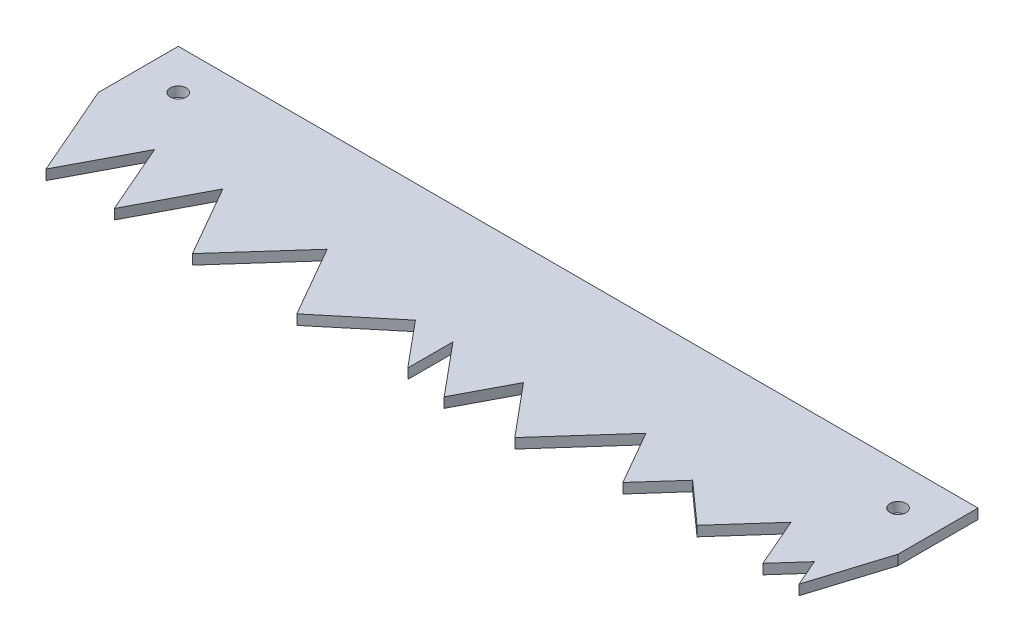
from build123d import *

# Parameters (mm, degrees)
SKETCH1_W           = 254
SKETCH1_H           = 25.4
BOSS_EXTRUDE1_DEPTH = 3.175
BOSS_EXTRUDE2_DEPTH = 3.175
SKETCH3_R           = 2.54
CUT_EXTRUDE2_DEPTH  = 4.175


with BuildPart() as part:
    # Sketch1 → Boss-Extrude1 (new body)
    with BuildSketch(Plane(origin=(0, 0, 0), x_dir=(1, 0, 0), z_dir=(0, 1, 0))):
        Rectangle(SKETCH1_W, SKETCH1_H)
    extrude(amount=BOSS_EXTRUDE1_DEPTH)

    # Sketch2 → Boss-Extrude2 (add)
    with BuildSketch(Plane(origin=(0, 3.175, 0), x_dir=(1, 0, 0), z_dir=(0, 1, 0))):
        Polygon((-127, -12.7), (-114.24505896, -42.072282192), (-102.377802862, -19.463351482), (-92.559853535, -42.072282192), (-80.692597436, -19.463351482), (-67.726112797, -42.072282192), (-47.545099388, -19.463351482), (-34.578614749, -42.072282192), (-14.024094064, -24.969728455), (-2.091376305, -39.310937246), (-2.091376305, -24.969728455), (11.649477697, -41.484026388), (20.317707317, -24.969728455), (34.058561319, -41.484026388), (53.714490264, -19.463351482), (63.583568446, -36.671508588), (74.028723274, -24.969728455), (87.13830954, -36.671508588), (101.210719192, -20.906089464), (108.056867206, -36.671508588), (115.76466778, -28.036405605), (119.514469334, -36.671508588), (127, -12.7), align=None)
    extrude(amount=-BOSS_EXTRUDE2_DEPTH)

    # Sketch3 → Cut-Extrude2 (cut, through all)
    with BuildSketch(Plane(origin=(0, 3.175, 0), x_dir=(1, 0, 0), z_dir=(0, 1, 0))):
        with Locations((-114.3, 0)):
            Circle(SKETCH3_R)
        with Locations((114.3, 0)):
            Circle(SKETCH3_R)
    extrude(amount=-CUT_EXTRUDE2_DEPTH, mode=Mode.SUBTRACT)


solid = part.part
